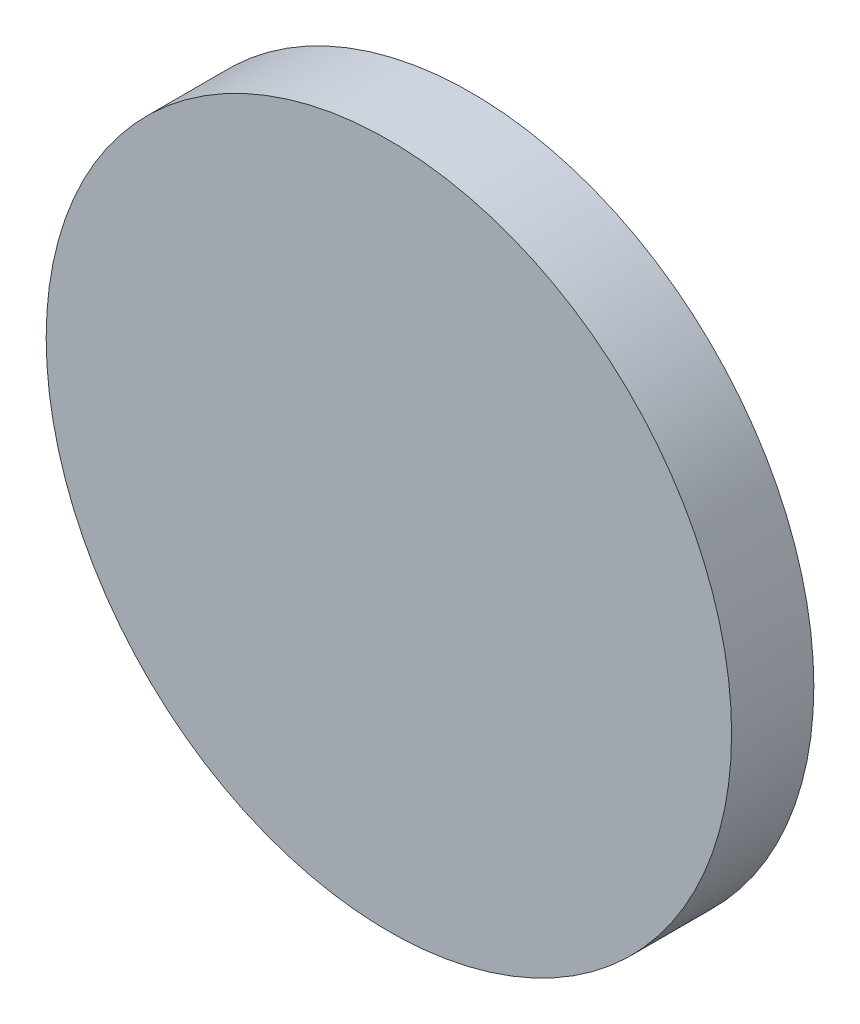
from build123d import *

# Parameters (mm, degrees)
SKETCH1_R           = 31.75
BOSS_EXTRUDE1_DEPTH = 7.62


with BuildPart() as part:
    # Sketch1 → Boss-Extrude1 (new body)
    with BuildSketch(Plane.XY):
        Circle(SKETCH1_R)
    extrude(amount=BOSS_EXTRUDE1_DEPTH)


solid = part.part
